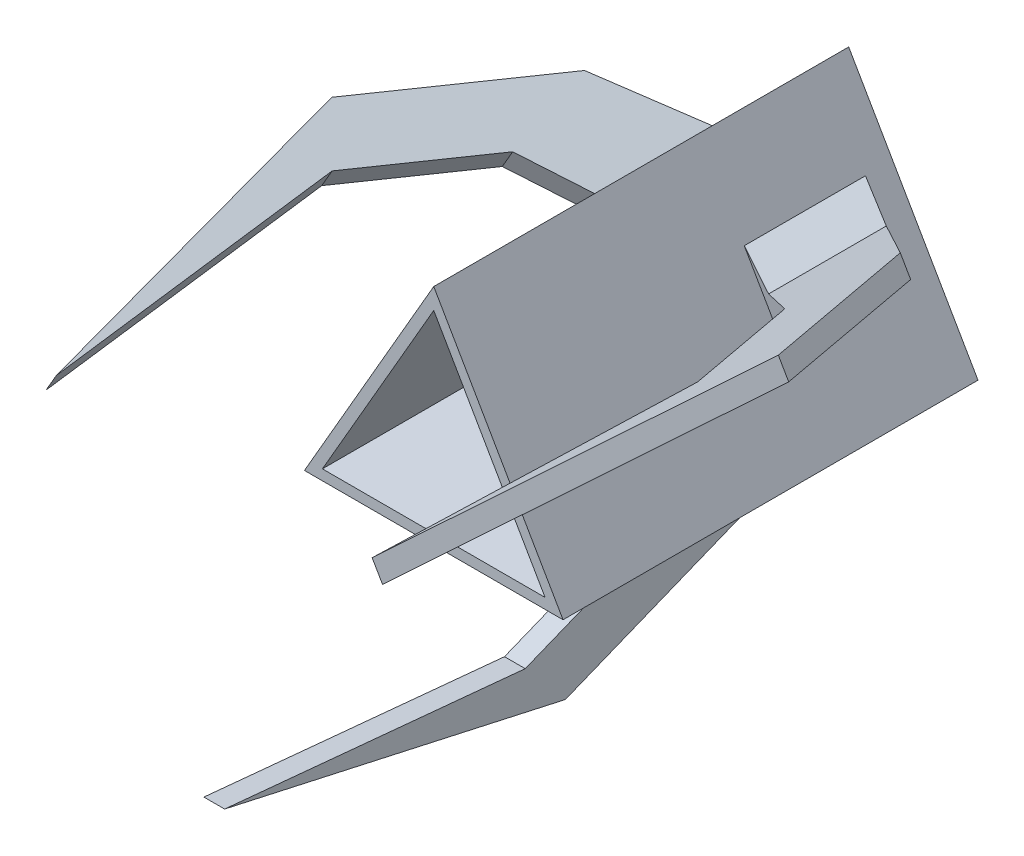
from build123d import *

# Parameters (mm, degrees)
BOSS_EXTRUDE1_DEPTH  = 10
SKETCH2_W            = 10.336230878
SKETCH2_H            = 10.881732654
SKETCH2_W_2          = 8
SKETCH2_H_2          = 9
BOSS_EXTRUDE2_DEPTH  = 10
EXTRUDE_THIN1_DEPTH  = 30
BOSS_EXTRUDE3_DEPTH  = 1
MIRROR2_COPY_1_DEPTH = 1
CHAMFER2_SIZE        = 3
CUT_EXTRUDE1_DEPTH   = 5


with BuildPart() as part:
    # Sketch1 → Boss-Extrude1 (new body)
    with BuildSketch(Plane.XY):
        Polygon((0, 14.392304845), (-12.464101615, -7.196152423), (12.464101615, -7.196152423), align=None)
        Polygon((0, 10.392304845), (-9, -5.196152423), (9, -5.196152423), align=None, mode=Mode.SUBTRACT)
    extrude(amount=BOSS_EXTRUDE1_DEPTH)

    # Sketch2 → Boss-Extrude2 (add)
    with BuildSketch(Plane.XY.offset(10)):
        Rectangle(SKETCH2_W, SKETCH2_H)
        Rectangle(SKETCH2_W_2, SKETCH2_H_2, mode=Mode.SUBTRACT)
    extrude(amount=-BOSS_EXTRUDE2_DEPTH)

    # Sketch3 → Extrude-Thin1 (add)
    with BuildSketch(Plane.XY.offset(10)):
        Polygon((0, 14.392304845), (-12.464101615, -7.196152423), (12.464101615, -7.196152423), align=None)
        Polygon((0, 12.392304845), (-10.732050808, -6.196152423), (10.732050808, -6.196152423), align=None, mode=Mode.SUBTRACT)
    extrude(amount=EXTRUDE_THIN1_DEPTH)

    # Sketch4 → Boss-Extrude3 (add, symmetric)
    with BuildSketch(Plane(origin=(0, 0, 0), x_dir=(0.866025404, 0.5, 0), z_dir=(-0.5, 0.866025404, 0))):
        Polygon((7.196152423, -2.618036355), (7.196152423, -14.298247708), (15.718557778, -19.278268119), (20.919199073, -32.180049847), (18.151461796, -61.156795565), (25.431971062, -28.309033375), (18.151461796, -10.247502864), align=None)
    boss_extrude3 = extrude(amount=BOSS_EXTRUDE3_DEPTH, both=True)

    # Mirror1: Boss-Extrude3 across plane
    add(boss_extrude3.mirror(Plane(origin=(0, 0, 0), x_dir=(0, 0, 1), z_dir=(1, 0, 0))))

    # Mirror2: Boss-Extrude3 across plane
    add(boss_extrude3.mirror(Plane(origin=(0, 0, 0), x_dir=(0, 0, 1), z_dir=(-0.5, 0.866025404, 0))))

    # Mirror2 copy 1 sketch → Mirror2 copy 1 (add, symmetric)
    with BuildSketch(Plane(origin=(0, 0, 0), x_dir=(0, -1, 0), z_dir=(1, 0, 0))):
        Polygon((7.196152423, -2.618036355), (7.196152423, -14.298247708), (15.718557778, -19.278268119), (20.919199073, -32.180049847), (18.151461796, -61.156795565), (25.431971062, -28.309033375), (18.151461796, -10.247502864), align=None)
    extrude(amount=MIRROR2_COPY_1_DEPTH, both=True)

    # Chamfer2
    chamfer2_edges = [part.edges().sort_by_distance(p)[0] for p in [
        (6.732050808, 2.732050808, 8.458142032),
        (5.732050808, 4.464101615, 8.458142032),
        (-5.732050808, 4.464101615, 8.458142032),
        (-6.732050808, 2.732050808, 8.458142032),
        (-1, -7.196152423, 8.458142032),
        (1, -7.196152423, 8.458142032),
    ]]
    chamfer(chamfer2_edges, length=CHAMFER2_SIZE)

    # Sketch5 → Cut-Extrude1 (cut)
    with BuildSketch(Plane(origin=(0, 0, 0), x_dir=(-1, 0, 0), z_dir=(0, 0, -1))):
        Polygon((0, 10.392304845), (-9, -5.196152423), (9, -5.196152423), align=None)
    extrude(amount=-CUT_EXTRUDE1_DEPTH, mode=Mode.SUBTRACT)


solid = part.part
